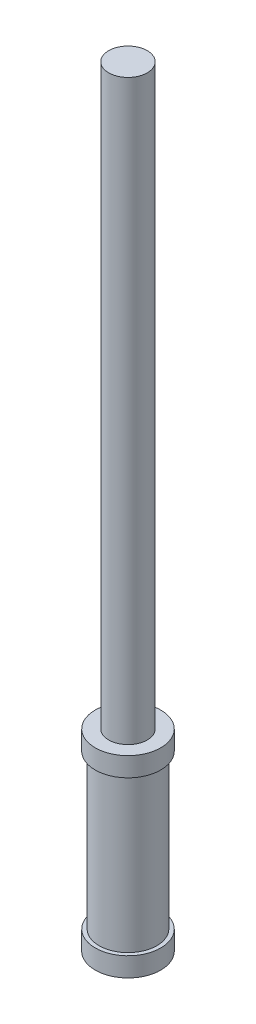
from build123d import *

# Parameters (mm, degrees)
SKETCH1_R           = 8.5
BOSS_EXTRUDE1_DEPTH = 50
SKETCH2_R           = 5
BOSS_EXTRUDE2_DEPTH = 150
SKETCH3_R           = 8.5
SKETCH3_R_2         = 7.5
CUT_EXTRUDE1_DEPTH  = 40


with BuildPart() as part:
    # Sketch1 → Boss-Extrude1 (new body)
    with BuildSketch(Plane(origin=(0, 0, 0), x_dir=(1, 0, 0), z_dir=(0, 1, 0))):
        Circle(SKETCH1_R)
    extrude(amount=BOSS_EXTRUDE1_DEPTH)

    # Sketch2 → Boss-Extrude2 (add)
    with BuildSketch(Plane(origin=(0, 50, 0), x_dir=(1, 0, 0), z_dir=(0, 1, 0))):
        Circle(SKETCH2_R)
    extrude(amount=BOSS_EXTRUDE2_DEPTH)

    # Sketch3 → Cut-Extrude1 (cut)
    with BuildSketch(Plane(origin=(0, 45, 0), x_dir=(1, 0, 0), z_dir=(0, 1, 0))):
        Circle(SKETCH3_R)
        Circle(SKETCH3_R_2, mode=Mode.SUBTRACT)
    extrude(amount=-CUT_EXTRUDE1_DEPTH, mode=Mode.SUBTRACT)


solid = part.part
